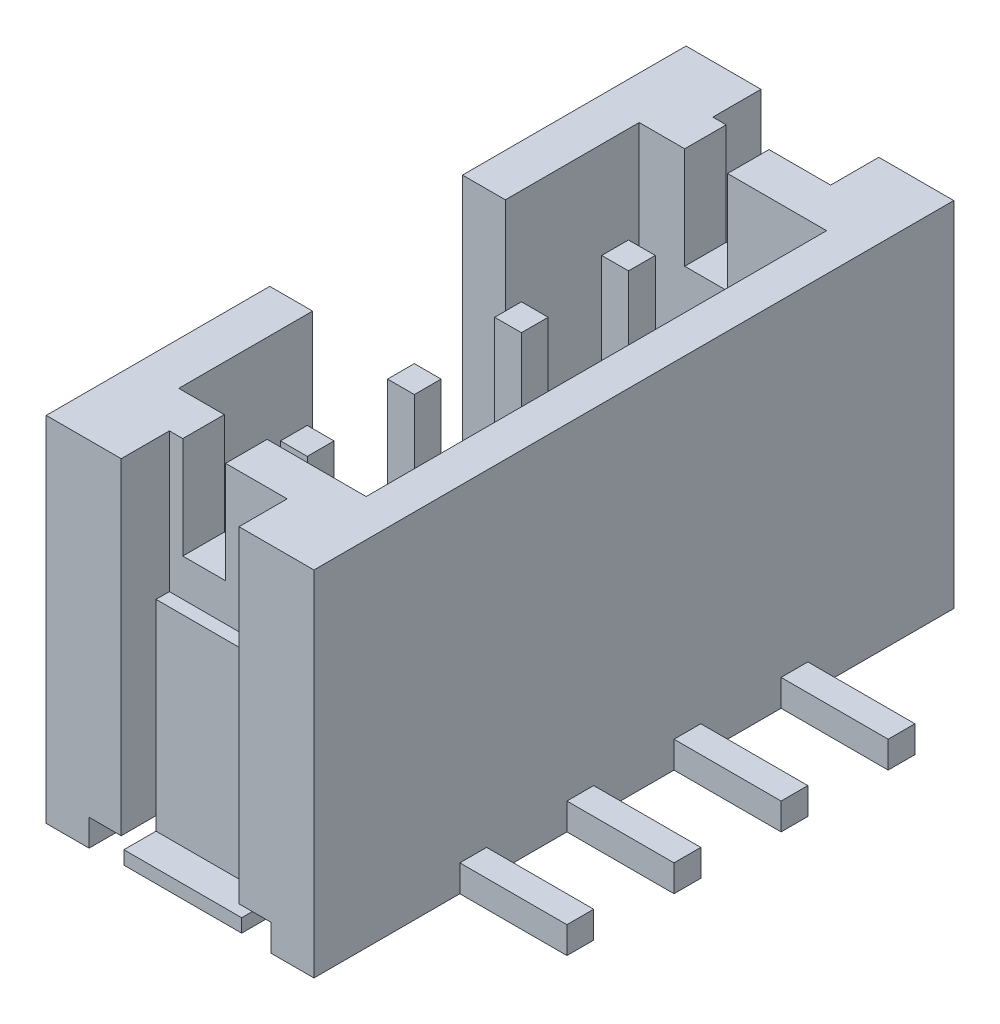
from build123d import *

# Parameters (mm, degrees)
SKETCH1_W            = 6.6
SKETCH1_H            = 11.95
BOSS_EXTRUDE1_DEPTH  = 5
SKETCH2_W            = 3.4
SKETCH2_H            = 0.5
CUT_EXTRUDE1_DEPTH   = 1.4
SKETCH3_W            = 2.2
SKETCH3_H            = 0.65
CUT_EXTRUDE2_DEPTH   = 7.1
SKETCH4_W            = 2.2
SKETCH4_H            = 0.25
BOSS_EXTRUDE2_DEPTH  = 0.5
SKETCH5_W            = 2.2
SKETCH5_H            = 0.25
BOSS_EXTRUDE3_DEPTH  = 0.6
SKETCH6_W            = 3.4
SKETCH6_H            = 0.5
CUT_EXTRUDE3_DEPTH   = 1.4
SKETCH7_W            = 2.2
SKETCH7_H            = 0.65
CUT_EXTRUDE4_DEPTH   = 7.1
SKETCH8_W            = 2.2
SKETCH8_H            = 0.25
BOSS_EXTRUDE4_DEPTH  = 0.5
SKETCH9_W            = 2.2
SKETCH9_H            = 0.25
BOSS_EXTRUDE5_DEPTH  = 0.6
CUT_EXTRUDE5_DEPTH   = 3.6
CUT_EXTRUDE6_REACH   = 2.9
SKETCH12_W           = 2.2
SKETCH12_H           = 2.6
CUT_EXTRUDE7_REACH   = 12.275
SKETCH13_W           = 1.85
SKETCH13_H           = 4.85
SKETCH14_W           = 2.5
SKETCH14_H           = 4.25
CUT_EXTRUDE8_DEPTH   = 1.65
CUT_EXTRUDE9_REACH   = 2.9
SKETCH16_W           = 2.2
SKETCH16_H           = 2.6
CUT_EXTRUDE10_REACH  = 12.275
SKETCH17_W           = 1.85
SKETCH17_H           = 4.85
SKETCH18_W           = 2.5
SKETCH18_H           = 4.25
CUT_EXTRUDE11_DEPTH  = 1.65
CUT_EXTRUDE12_REACH  = 6.85
SKETCH20_W           = 0.8
SKETCH20_H           = 3.6
SKETCH21_W           = 0.8
SKETCH21_H           = 1.9
CUT_EXTRUDE13_DEPTH  = 2.675
SKETCH22_W           = 0.8
SKETCH22_H           = 1.9
CUT_EXTRUDE14_DEPTH  = 2.675
SKETCH23_W           = 0.5
SKETCH23_H           = 0.5
BOSS_EXTRUDE6_DEPTH  = 2
SKETCH24_W           = 0.5
SKETCH24_H           = 0.5
BOSS_EXTRUDE7_DEPTH  = 2
SKETCH25_W           = 0.5
SKETCH25_H           = 0.5
BOSS_EXTRUDE8_DEPTH  = 2
SKETCH26_W           = 0.5
SKETCH26_H           = 0.5
BOSS_EXTRUDE9_DEPTH  = 2
SKETCH27_W           = 0.5
SKETCH27_H           = 0.5
BOSS_EXTRUDE10_DEPTH = 3.3
SKETCH28_W           = 0.5
SKETCH28_H           = 0.5
BOSS_EXTRUDE11_DEPTH = 3.3
SKETCH29_W           = 0.5
SKETCH29_H           = 0.5
BOSS_EXTRUDE12_DEPTH = 3.3
SKETCH30_W           = 0.5
SKETCH30_H           = 0.5
BOSS_EXTRUDE13_DEPTH = 3.3
DRAFT1_ANGLE         = 45


with BuildPart() as part:
    # Sketch1 → Boss-Extrude1 (new body)
    with BuildSketch(Plane(origin=(-5, 0, 0), x_dir=(0, -1, 0), z_dir=(-1, 0, 0))):
        with Locations((-3.3, 0)):
            Rectangle(SKETCH1_W, SKETCH1_H)
    extrude(amount=-BOSS_EXTRUDE1_DEPTH)

    # Sketch2 → Cut-Extrude1 (cut)
    with BuildSketch(Plane.XY.offset(5.975)):
        with Locations((-2.5, 0.25)):
            Rectangle(SKETCH2_W, SKETCH2_H)
    extrude(amount=-CUT_EXTRUDE1_DEPTH, mode=Mode.SUBTRACT)

    # Sketch3 → Cut-Extrude2 (cut, through all)
    with BuildSketch(Plane.XZ.offset(-0.5)):
        with Locations((-2.5, 5.65)):
            Rectangle(SKETCH3_W, SKETCH3_H)
    extrude(amount=-CUT_EXTRUDE2_DEPTH, mode=Mode.SUBTRACT)

    # Sketch4 → Boss-Extrude2 (add)
    with BuildSketch(Plane.XZ.offset(-0.5)):
        with Locations((-2.5, 5.2)):
            Rectangle(SKETCH4_W, SKETCH4_H)
    extrude(amount=BOSS_EXTRUDE2_DEPTH)

    # Sketch5 → Boss-Extrude3 (add)
    with BuildSketch(Plane.XY.offset(5.325)):
        with Locations((-2.5, 0.125)):
            Rectangle(SKETCH5_W, SKETCH5_H)
    extrude(amount=BOSS_EXTRUDE3_DEPTH)

    # Sketch6 → Cut-Extrude3 (cut)
    with BuildSketch(Plane(origin=(0, 0, -5.975), x_dir=(-1, 0, 0), z_dir=(0, 0, -1))):
        with Locations((2.5, 0.25)):
            Rectangle(SKETCH6_W, SKETCH6_H)
    extrude(amount=-CUT_EXTRUDE3_DEPTH, mode=Mode.SUBTRACT)

    # Sketch7 → Cut-Extrude4 (cut, through all)
    with BuildSketch(Plane.XZ.offset(-0.5)):
        with Locations((-2.5, -5.65)):
            Rectangle(SKETCH7_W, SKETCH7_H)
    extrude(amount=-CUT_EXTRUDE4_DEPTH, mode=Mode.SUBTRACT)

    # Sketch8 → Boss-Extrude4 (add)
    with BuildSketch(Plane.XZ.offset(-0.5)):
        with Locations((-2.5, -5.2)):
            Rectangle(SKETCH8_W, SKETCH8_H)
    extrude(amount=BOSS_EXTRUDE4_DEPTH)

    # Sketch9 → Boss-Extrude5 (add)
    with BuildSketch(Plane(origin=(0, 0, -5.325), x_dir=(-1, 0, 0), z_dir=(0, 0, -1))):
        with Locations((2.5, 0.125)):
            Rectangle(SKETCH9_W, SKETCH9_H)
    extrude(amount=BOSS_EXTRUDE5_DEPTH)

    # Sketch10 → Cut-Extrude5 (cut)
    with BuildSketch(Plane(origin=(0, 0, -1.8), x_dir=(-1, 0, 0), z_dir=(0, 0, -1))):
        Polygon((5, 2.35), (5, 6.6), (0.7, 6.6), (0.7, 1.75), (2.55, 1.75), (2.55, 2.35), align=None)
    extrude(amount=-CUT_EXTRUDE5_DEPTH, mode=Mode.SUBTRACT)

    # Sketch12 → Cut-Extrude6 (cut, up to next)
    with BuildSketch(Plane(origin=(0, 0, 5.075), x_dir=(-1, 0, 0), z_dir=(0, 0, -1)), mode=Mode.PRIVATE) as cut_extrude6_sk1:
        with Locations((2.5, 5.3)):
            Rectangle(SKETCH12_W, SKETCH12_H)
    cut_extrude6_tool1 = extrude(cut_extrude6_sk1.sketch, amount=-CUT_EXTRUDE6_REACH, mode=Mode.PRIVATE) & part.part
    add(cut_extrude6_tool1.solids().sort_by_distance((-2.5, 5.3, 5.075))[0], mode=Mode.SUBTRACT)

    # Sketch13 → Cut-Extrude7 (cut, up to next)
    with BuildSketch(Plane.XY.offset(4.3), mode=Mode.PRIVATE) as cut_extrude7_sk1:
        with Locations((-1.625, 4.175)):
            Rectangle(SKETCH13_W, SKETCH13_H)
    cut_extrude7_tool1 = extrude(cut_extrude7_sk1.sketch, amount=-CUT_EXTRUDE7_REACH, mode=Mode.PRIVATE) & part.part
    add(cut_extrude7_tool1.solids().sort_by_distance((-1.625, 4.175, 4.3))[0], mode=Mode.SUBTRACT)

    # Sketch14 → Cut-Extrude8 (cut)
    with BuildSketch(Plane(origin=(-2.55, 0, 0), x_dir=(0, 0, -1), z_dir=(1, 0, 0))):
        with Locations((-3.05, 4.475)):
            Rectangle(SKETCH14_W, SKETCH14_H)
    extrude(amount=-CUT_EXTRUDE8_DEPTH, mode=Mode.SUBTRACT)

    # Sketch16 → Cut-Extrude9 (cut, up to next)
    with BuildSketch(Plane.XY.offset(-5.075), mode=Mode.PRIVATE) as cut_extrude9_sk1:
        with Locations((-2.5, 5.3)):
            Rectangle(SKETCH16_W, SKETCH16_H)
    cut_extrude9_tool1 = extrude(cut_extrude9_sk1.sketch, amount=-CUT_EXTRUDE9_REACH, mode=Mode.PRIVATE) & part.part
    add(cut_extrude9_tool1.solids().sort_by_distance((-2.5, 5.3, -5.075))[0], mode=Mode.SUBTRACT)

    # Sketch17 → Cut-Extrude10 (cut, up to next)
    with BuildSketch(Plane(origin=(0, 0, -4.3), x_dir=(-1, 0, 0), z_dir=(0, 0, -1)), mode=Mode.PRIVATE) as cut_extrude10_sk1:
        with Locations((1.625, 4.175)):
            Rectangle(SKETCH17_W, SKETCH17_H)
    cut_extrude10_tool1 = extrude(cut_extrude10_sk1.sketch, amount=-CUT_EXTRUDE10_REACH, mode=Mode.PRIVATE) & part.part
    add(cut_extrude10_tool1.solids().sort_by_distance((-1.625, 4.175, -4.3))[0], mode=Mode.SUBTRACT)

    # Sketch18 → Cut-Extrude11 (cut)
    with BuildSketch(Plane(origin=(-2.55, 0, 0), x_dir=(0, 0, -1), z_dir=(1, 0, 0))):
        with Locations((3.05, 4.475)):
            Rectangle(SKETCH18_W, SKETCH18_H)
    extrude(amount=-CUT_EXTRUDE11_DEPTH, mode=Mode.SUBTRACT)

    # Sketch20 → Cut-Extrude12 (cut, up to next)
    with BuildSketch(Plane.XZ.offset(-1.75), mode=Mode.PRIVATE) as cut_extrude12_sk1:
        with Locations((-4.6, 0)):
            Rectangle(SKETCH20_W, SKETCH20_H)
    cut_extrude12_tool1 = extrude(cut_extrude12_sk1.sketch, amount=-CUT_EXTRUDE12_REACH, mode=Mode.PRIVATE) & part.part
    add(cut_extrude12_tool1.solids().sort_by_distance((-4.6, 1.75, 0))[0], mode=Mode.SUBTRACT)

    # Sketch21 → Cut-Extrude13 (cut, through all)
    with BuildSketch(Plane(origin=(0, 0, 4.3), x_dir=(-1, 0, 0), z_dir=(0, 0, -1))):
        with Locations((2.95, 5.65)):
            Rectangle(SKETCH21_W, SKETCH21_H)
    extrude(amount=-CUT_EXTRUDE13_DEPTH, mode=Mode.SUBTRACT)

    # Sketch22 → Cut-Extrude14 (cut, through all)
    with BuildSketch(Plane.XY.offset(-4.3)):
        with Locations((-2.95, 5.65)):
            Rectangle(SKETCH22_W, SKETCH22_H)
    extrude(amount=-CUT_EXTRUDE14_DEPTH, mode=Mode.SUBTRACT)

    # Sketch23 → Boss-Extrude6 (add)
    with BuildSketch(Plane(origin=(0, 0, 0), x_dir=(0, 0, -1), z_dir=(1, 0, 0))):
        with Locations((-3, 0.25)):
            Rectangle(SKETCH23_W, SKETCH23_H)
    extrude(amount=BOSS_EXTRUDE6_DEPTH)

    # Sketch24 → Boss-Extrude7 (add)
    with BuildSketch(Plane(origin=(0, 0, 0), x_dir=(0, 0, -1), z_dir=(1, 0, 0))):
        with Locations((-1, 0.25)):
            Rectangle(SKETCH24_W, SKETCH24_H)
    extrude(amount=BOSS_EXTRUDE7_DEPTH)

    # Sketch25 → Boss-Extrude8 (add)
    with BuildSketch(Plane(origin=(0, 0, 0), x_dir=(0, 0, -1), z_dir=(1, 0, 0))):
        with Locations((1, 0.25)):
            Rectangle(SKETCH25_W, SKETCH25_H)
    extrude(amount=BOSS_EXTRUDE8_DEPTH)

    # Sketch26 → Boss-Extrude9 (add)
    with BuildSketch(Plane(origin=(0, 0, 0), x_dir=(0, 0, -1), z_dir=(1, 0, 0))):
        with Locations((3, 0.25)):
            Rectangle(SKETCH26_W, SKETCH26_H)
    extrude(amount=BOSS_EXTRUDE9_DEPTH)

    # Sketch27 → Boss-Extrude10 (add)
    with BuildSketch(Plane(origin=(0, 2.35, 0), x_dir=(-1, 0, 0), z_dir=(0, 1, 0))):
        with Locations((3.1, -3)):
            Rectangle(SKETCH27_W, SKETCH27_H)
    extrude(amount=BOSS_EXTRUDE10_DEPTH)

    # Sketch28 → Boss-Extrude11 (add)
    with BuildSketch(Plane(origin=(0, 2.35, 0), x_dir=(-1, 0, 0), z_dir=(0, 1, 0))):
        with Locations((3.1, -1)):
            Rectangle(SKETCH28_W, SKETCH28_H)
    extrude(amount=BOSS_EXTRUDE11_DEPTH)

    # Sketch29 → Boss-Extrude12 (add)
    with BuildSketch(Plane(origin=(0, 2.35, 0), x_dir=(-1, 0, 0), z_dir=(0, 1, 0))):
        with Locations((3.1, 1)):
            Rectangle(SKETCH29_W, SKETCH29_H)
    extrude(amount=BOSS_EXTRUDE12_DEPTH)

    # Sketch30 → Boss-Extrude13 (add)
    with BuildSketch(Plane(origin=(0, 2.35, 0), x_dir=(-1, 0, 0), z_dir=(0, 1, 0))):
        with Locations((3.1, 3)):
            Rectangle(SKETCH30_W, SKETCH30_H)
    extrude(amount=BOSS_EXTRUDE13_DEPTH)

    # Draft1
    draft1_faces = [part.faces().sort_by_distance(p)[0] for p in [
        (-2.55, 2.05, 0),
    ]]
    draft(draft1_faces, Plane(origin=(-2.55, 2.35, 1.8), x_dir=(0, 0, 1), z_dir=(0, 1, 0)), DRAFT1_ANGLE)


solid = part.part
